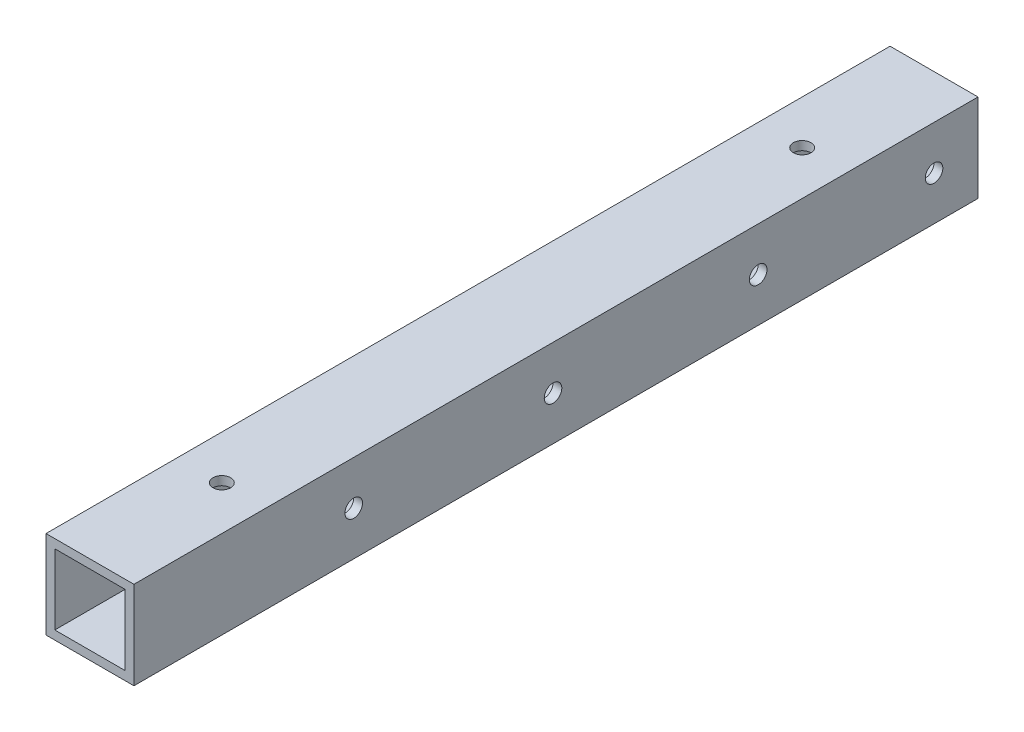
from build123d import *

# Parameters (mm, degrees)
SKETCH_1_W           = 15
SKETCH_1_H           = 15
SKETCH_1_W_2         = 12
SKETCH_1_H_2         = 12
EXTRUDE_2_DEPTH      = 144
SKETCH_3_R           = 1.5
CUT_EXTRUDE_2_DEPTH  = 10
SKETCH_4_R           = 1.5
CUT_EXTRUDE_4_DEPTH  = 10
SKETCH_7_R           = 4
CUT_EXTRUDE_6_DEPTH  = 10
SKETCH_8_R           = 4
CUT_EXTRUDE_7_DEPTH  = 10
SKETCH_9_R           = 6
CUT_EXTRUDE_8_DEPTH  = 10
SKETCH_10_R          = 1.5
CUT_EXTRUDE_9_DEPTH  = 10
SKETCH_11_R          = 4
CUT_EXTRUDE_10_DEPTH = 10
SKETCH_12_R          = 6
CUT_EXTRUDE_11_DEPTH = 10
SKETCH_13_R          = 1.5
CUT_EXTRUDE_12_DEPTH = 10
SKETCH_14_R          = 1.5
CUT_EXTRUDE_13_DEPTH = 10
SKETCH_15_R          = 1.5
CUT_EXTRUDE_14_DEPTH = 10


with BuildPart() as part:
    # ｽｹｯﾁ1 → ﾎﾞｽ - 押し出し2 (new body)
    with BuildSketch(Plane.XY):
        with Locations((0.489915859, 0.232626086)):
            Rectangle(SKETCH_1_W, SKETCH_1_H)
        with Locations((0.489915859, 0.232626086)):
            Rectangle(SKETCH_1_W_2, SKETCH_1_H_2, mode=Mode.SUBTRACT)
    extrude(amount=EXTRUDE_2_DEPTH)

    # ｽｹｯﾁ3 → ｶｯﾄ - 押し出し2 (cut)
    with BuildSketch(Plane(origin=(0, 7.732626086, 0), x_dir=(1, 0, 0), z_dir=(0, 1, 0))):
        with Locations((0.489915859, -22.5)):
            Circle(SKETCH_3_R)
    extrude(amount=-CUT_EXTRUDE_2_DEPTH, mode=Mode.SUBTRACT)

    # ｽｹｯﾁ4 → ｶｯﾄ - 押し出し4 (cut)
    with BuildSketch(Plane(origin=(0, 7.732626086, 0), x_dir=(1, 0, 0), z_dir=(0, 1, 0))):
        with Locations((0.489915859, -121.5)):
            Circle(SKETCH_4_R)
    extrude(amount=-CUT_EXTRUDE_4_DEPTH, mode=Mode.SUBTRACT)

    # ｽｹｯﾁ7 → ｶｯﾄ - 押し出し6 (cut)
    with BuildSketch(Plane.XZ.offset(7.267373914)):
        with Locations((0.489915859, 22.5)):
            Circle(SKETCH_7_R)
    extrude(amount=-CUT_EXTRUDE_6_DEPTH, mode=Mode.SUBTRACT)

    # ｽｹｯﾁ8 → ｶｯﾄ - 押し出し7 (cut)
    with BuildSketch(Plane.XZ.offset(7.267373914)):
        with Locations((0.489915859, 121.5)):
            Circle(SKETCH_8_R)
    extrude(amount=-CUT_EXTRUDE_7_DEPTH, mode=Mode.SUBTRACT)

    # ｽｹｯﾁ9 → ｶｯﾄ - 押し出し8 (cut)
    with BuildSketch(Plane.ZY.offset(7.010084141)):
        with Locations((37.5, 0.232626086)):
            Circle(SKETCH_9_R)
    extrude(amount=-CUT_EXTRUDE_8_DEPTH, mode=Mode.SUBTRACT)

    # ｽｹｯﾁ10 → ｶｯﾄ - 押し出し9 (cut)
    with BuildSketch(Plane(origin=(7.989915859, 0, 0), x_dir=(0, 0, -1), z_dir=(1, 0, 0))):
        with Locations((-37.5, 0.232626086)):
            Circle(SKETCH_10_R)
    extrude(amount=-CUT_EXTRUDE_9_DEPTH, mode=Mode.SUBTRACT)

    # ｽｹｯﾁ11 → ｶｯﾄ - 押し出し10 (cut)
    with BuildSketch(Plane.XZ.offset(7.267373914)):
        with Locations((0.489915859, 72.5)):
            Circle(SKETCH_11_R)
    extrude(amount=-CUT_EXTRUDE_10_DEPTH, mode=Mode.SUBTRACT)

    # ｽｹｯﾁ12 → ｶｯﾄ - 押し出し11 (cut)
    with BuildSketch(Plane.ZY.offset(7.010084141)):
        with Locations((106.5, 0.232626086)):
            Circle(SKETCH_12_R)
    extrude(amount=-CUT_EXTRUDE_11_DEPTH, mode=Mode.SUBTRACT)

    # ｽｹｯﾁ13 → ｶｯﾄ - 押し出し12 (cut)
    with BuildSketch(Plane(origin=(7.989915859, 0, 0), x_dir=(0, 0, -1), z_dir=(1, 0, 0))):
        with Locations((-106.5, 0.232626086)):
            Circle(SKETCH_13_R)
    extrude(amount=-CUT_EXTRUDE_12_DEPTH, mode=Mode.SUBTRACT)

    # ｽｹｯﾁ14 → ｶｯﾄ - 押し出し13 (cut)
    with BuildSketch(Plane(origin=(7.989915859, 0, 0), x_dir=(0, 0, -1), z_dir=(1, 0, 0))):
        with Locations((-7.5, 0.232626086)):
            Circle(SKETCH_14_R)
    extrude(amount=-CUT_EXTRUDE_13_DEPTH, mode=Mode.SUBTRACT)

    # ｽｹｯﾁ15 → ｶｯﾄ - 押し出し14 (cut)
    with BuildSketch(Plane(origin=(7.989915859, 0, 0), x_dir=(0, 0, -1), z_dir=(1, 0, 0))):
        with Locations((-72.5, 0.232626086)):
            Circle(SKETCH_15_R)
    extrude(amount=-CUT_EXTRUDE_14_DEPTH, mode=Mode.SUBTRACT)


solid = part.part
